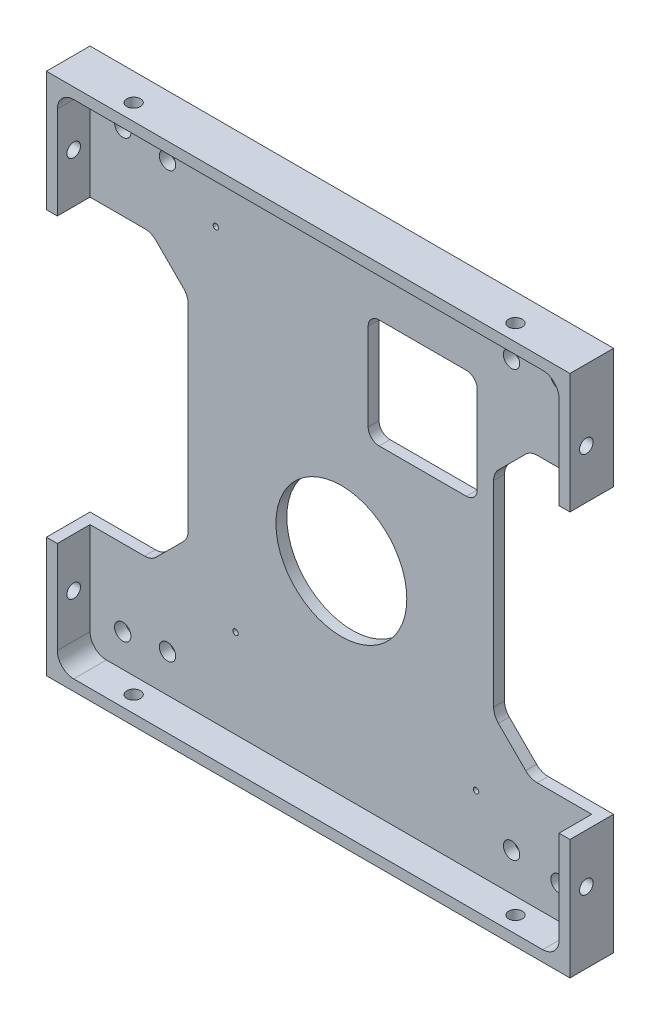
from build123d import *

# Parameters (mm, degrees)
SKETCH1_W                      = 96
SKETCH1_H                      = 96
BOSS_EXTRUDE1_DEPTH            = 8
SKETCH2_W                      = 92
SKETCH2_H                      = 92
COMPONENT_PLATFORM_DEPTH       = 6
CABLE_SLOTS_DEPTH              = 6
INNER_CORNER_FILLETS_R         = 3
M3X0_5_TAPPED_HOLE1_AT_2_COUNT = 2
M3X0_5_TAPPED_HOLE1_AT_2_PITCH = 70
M3X0_5_TAPPED_HOLE2_AT_2_COUNT = 2
M3X0_5_TAPPED_HOLE2_AT_2_PITCH = 70
F_1_0MM_DOWEL_HOLE1_D          = 1
F_1_0MM_DOWEL_HOLE1_DEPTH      = 3.7
F_1_0MM_DOWEL_HOLE1_TIP        = 0.30043031
SKETCH29_R                     = 12
HDD_EXTRUSION_CUTOUT_DEPTH     = 10
HDD_EXTRUSION_CUTOUT_2_DEPTH   = 10
F_3_0MM_DOWEL_HOLE1_D          = 3
F_3_0MM_DOWEL_HOLE1_DEPTH      = 2
F_3_0MM_DOWEL_HOLE2_D          = 3


with BuildPart() as part:
    # Sketch1 → Boss-Extrude1 (new body)
    with BuildSketch(Plane.XY):
        Rectangle(SKETCH1_W, SKETCH1_H)
    extrude(amount=BOSS_EXTRUDE1_DEPTH)

    # Sketch2 → Component Platform (cut)
    with BuildSketch(Plane.XY.offset(8)):
        Rectangle(SKETCH2_W, SKETCH2_H)
    extrude(amount=-COMPONENT_PLATFORM_DEPTH, mode=Mode.SUBTRACT)

    # Sketch3 → Cable Slots (cut, symmetric)
    with BuildSketch(Plane.XY.offset(2)):
        with BuildLine():
            Line((-33.878679656, -25.121320344), (-28.878679656, -20.121320344))
            ThreePointArc((-28.878679656, -20.121320344), (-28.228361402, -19.148050297), (-28, -18))
            Line((-28, -18), (-28, 18))
            ThreePointArc((-28, 18), (-28.228361402, 19.148050297), (-28.878679656, 20.121320344))
            Line((-28.878679656, 20.121320344), (-33.878679656, 25.121320344))
            ThreePointArc((-33.878679656, 25.121320344), (-34.851949703, 25.771638598), (-36, 26))
            Line((-36, 26), (-48, 26))
            Line((-48, 26), (-48, -26))
            Line((-48, -26), (-36, -26))
            ThreePointArc((-36, -26), (-34.851949703, -25.771638598), (-33.878679656, -25.121320344))
        make_face()
        with BuildLine():
            Line((48, -26), (48, 26))
            Line((48, 26), (36, 26))
            ThreePointArc((36, 26), (34.851949703, 25.771638598), (33.878679656, 25.121320344))
            Line((33.878679656, 25.121320344), (28.878679656, 20.121320344))
            ThreePointArc((28.878679656, 20.121320344), (28.228361402, 19.148050297), (28, 18))
            Line((28, 18), (28, -18))
            ThreePointArc((28, -18), (28.228361402, -19.148050297), (28.878679656, -20.121320344))
            Line((28.878679656, -20.121320344), (33.878679656, -25.121320344))
            ThreePointArc((33.878679656, -25.121320344), (34.851949703, -25.771638598), (36, -26))
            Line((36, -26), (48, -26))
        make_face()
    extrude(amount=CABLE_SLOTS_DEPTH, both=True, mode=Mode.SUBTRACT)

    # Inner Corner Fillets
    inner_corner_fillets_edges = [part.edges().sort_by_distance(p)[0] for p in [
        (-46, -46, 5),
        (-46, 46, 5),
        (46, 46, 5),
        (46, -46, 5),
    ]]
    fillet(inner_corner_fillets_edges, radius=INNER_CORNER_FILLETS_R)

    # Sketch14 → M3x0.5 Tapped Hole1 (revolve, cut)
    with BuildSketch(Plane(origin=(48, -35, 5), x_dir=(0, 0, -1), z_dir=(0, 1, 0))):
        Polygon((0, 0), (0, 10.751075774), (1.25, 10), (1.25, 0), align=None)
    m3x0_5_tapped_hole1 = revolve(axis=Axis((54.35, -35, 5), (-1, 0, 0)), mode=Mode.SUBTRACT)

    # M3x0.5 Tapped Hole1 at 2: M3x0.5 Tapped Hole1 ×2
    with Locations(*[(0, i * M3X0_5_TAPPED_HOLE1_AT_2_PITCH, 0) for i in range(1, M3X0_5_TAPPED_HOLE1_AT_2_COUNT)]):
        add(m3x0_5_tapped_hole1, mode=Mode.SUBTRACT)

    # Sketch16 → M3x0.5 Tapped Hole2 (revolve, cut)
    with BuildSketch(Plane(origin=(35, 48, 5), x_dir=(0, 0, 1), z_dir=(1, 0, 0))):
        Polygon((0, 0), (0, 10.751075774), (1.25, 10), (1.25, 0), align=None)
    m3x0_5_tapped_hole2 = revolve(axis=Axis((35, 54.35, 5), (0, -1, 0)), mode=Mode.SUBTRACT)

    # M3x0.5 Tapped Hole2 at 2: M3x0.5 Tapped Hole2 ×2
    with Locations(*[(-i * M3X0_5_TAPPED_HOLE2_AT_2_PITCH, 0, 0) for i in range(1, M3X0_5_TAPPED_HOLE2_AT_2_COUNT)]):
        add(m3x0_5_tapped_hole2, mode=Mode.SUBTRACT)

    # Mirror1: M3x0.5 Tapped Hole1 across plane
    add(m3x0_5_tapped_hole1.mirror(Plane(origin=(0, 0, 0), x_dir=(0, 0, 1), z_dir=(1, 0, 0))), mode=Mode.SUBTRACT)

    # Mirror1 copy 1 sketch → Mirror1 copy 1 (revolve, cut)
    with BuildSketch(Plane(origin=(-48, 35, 5), x_dir=(0, 0, -1), z_dir=(0, 1, 0))):
        Polygon((0, 0), (0, -10.751075774), (1.25, -10), (1.25, 0), align=None)
    revolve(axis=Axis((-54.35, 35, 5), (-1, 0, 0)), mode=Mode.SUBTRACT)

    # Mirror2: M3x0.5 Tapped Hole2 across plane
    add(m3x0_5_tapped_hole2.mirror(Plane(origin=(0, 0, 0), x_dir=(0, 0, 1), z_dir=(0, -1, 0))), mode=Mode.SUBTRACT)

    # Mirror2 copy 1 sketch → Mirror2 copy 1 (revolve, cut)
    with BuildSketch(Plane(origin=(-35, -48, 5), x_dir=(0, 0, 1), z_dir=(1, 0, 0))):
        Polygon((0, 0), (0, -10.751075774), (1.25, -10), (1.25, 0), align=None)
    revolve(axis=Axis((-35, -54.35, 5), (0, -1, 0)), mode=Mode.SUBTRACT)

    # Ø1.0mm Dowel Hole1
    with Locations(Plane.XY.offset(2)):
        with Locations((-19.31998517, -29.75), (24.78001483, -32.85), (-22.91998517, 32.85)):
            Hole(F_1_0MM_DOWEL_HOLE1_D / 2, depth=F_1_0MM_DOWEL_HOLE1_DEPTH)
            with Locations((0, 0, -(F_1_0MM_DOWEL_HOLE1_DEPTH + F_1_0MM_DOWEL_HOLE1_TIP / 2))):  # 118° drill point
                Cone(0, F_1_0MM_DOWEL_HOLE1_D / 2, F_1_0MM_DOWEL_HOLE1_TIP, mode=Mode.SUBTRACT)

    # Sketch29 → HDD Extrusion Cutout (cut)
    with BuildSketch(Plane(origin=(0, 0, 0), x_dir=(-1, 0, 0), z_dir=(0, 0, -1))):
        with Locations((-0.08192631, -8.74785827)):
            Circle(SKETCH29_R)
    extrude(amount=-HDD_EXTRUSION_CUTOUT_DEPTH, mode=Mode.SUBTRACT)

    # Sketch9 → HDD Extrusion Cutout 2 (cut)
    with BuildSketch(Plane.XY.offset(2)):
        with BuildLine():
            Line((25, 31), (25, 15))
            ThreePointArc((25, 15), (24.414213562, 13.585786438), (23, 13))
            Line((23, 13), (7, 13))
            ThreePointArc((7, 13), (5.585786438, 13.585786438), (5, 15))
            Line((5, 15), (5, 31))
            ThreePointArc((5, 31), (5.585786438, 32.414213562), (7, 33))
            Line((7, 33), (23, 33))
            ThreePointArc((23, 33), (24.414213562, 32.414213562), (25, 31))
        make_face()
    extrude(amount=-HDD_EXTRUSION_CUTOUT_2_DEPTH, mode=Mode.SUBTRACT)

    # Ø3.0mm Dowel Hole1
    with Locations(Plane.XY.offset(2)):
        with Locations((-31.790998517, -39.06), (31.29001483, -39.06), (31.29001483, 38.94), (-31.790998517, 38.94)):
            Hole(F_3_0MM_DOWEL_HOLE1_D / 2, depth=F_3_0MM_DOWEL_HOLE1_DEPTH)

    # Ø3.0mm Dowel Hole2 (through all)
    with Locations(Plane.XY.offset(2)):
        with Locations((40, -40), (-40, -40), (-40, 40), (40, 40)):
            Hole(F_3_0MM_DOWEL_HOLE2_D / 2)


solid = part.part
